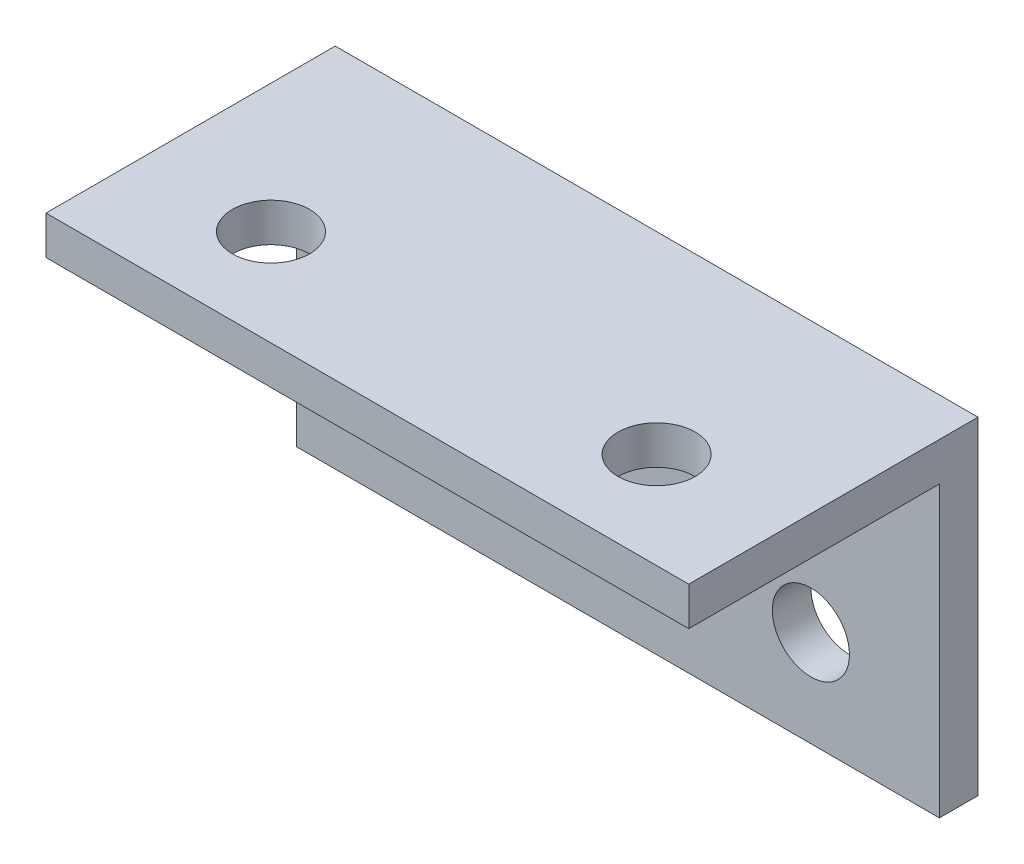
from build123d import *

# Parameters (mm, degrees)
SKETCH1_W           = 50
SKETCH1_H           = 22.5
SKETCH1_R           = 3
BOSS_EXTRUDE1_DEPTH = 3
SKETCH3_W           = 50
SKETCH3_H           = 22.5
SKETCH3_R           = 3
BOSS_EXTRUDE2_DEPTH = 3


with BuildPart() as part:
    # Sketch1 → Boss-Extrude1 (new body)
    with BuildSketch(Plane.XY):
        with Locations((-17.806163097, -13.303318659)):
            Rectangle(SKETCH1_W, SKETCH1_H)
        with Locations((-2.806163097, -17.053318659)):
            Circle(SKETCH1_R, mode=Mode.SUBTRACT)
        with Locations((-32.806163097, -17.053318659)):
            Circle(SKETCH1_R, mode=Mode.SUBTRACT)
    extrude(amount=BOSS_EXTRUDE1_DEPTH)

    # Sketch3 → Boss-Extrude2 (add)
    with BuildSketch(Plane(origin=(0, -2.053318659, 0), x_dir=(1, 0, 0), z_dir=(0, 1, 0))):
        with Locations((-17.806163097, -11.25)):
            Rectangle(SKETCH3_W, SKETCH3_H)
        with Locations((-2.806163097, -15)):
            Circle(SKETCH3_R, mode=Mode.SUBTRACT)
        with Locations((-32.806163097, -15)):
            Circle(SKETCH3_R, mode=Mode.SUBTRACT)
    extrude(amount=BOSS_EXTRUDE2_DEPTH)


solid = part.part
